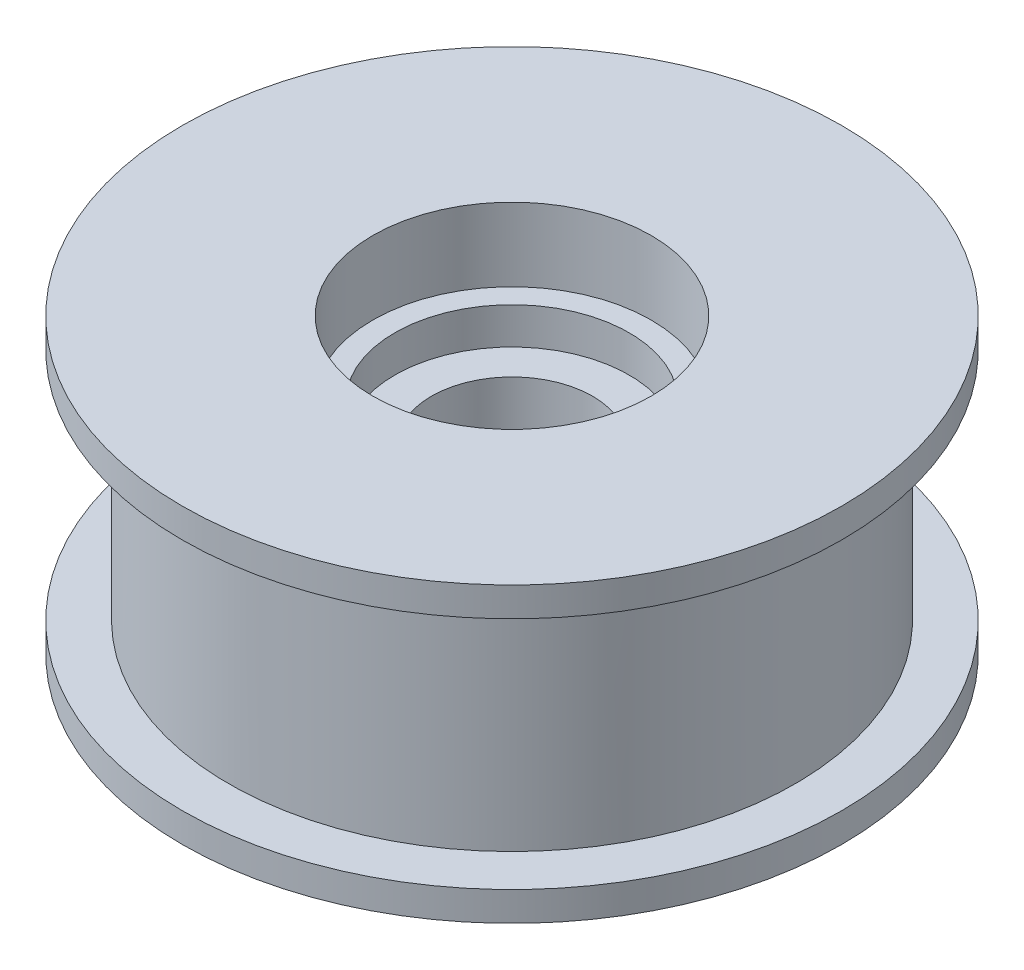
from build123d import *

# Parameters (mm, degrees)
SKETCH_1_R             = 19.325
SKETCH_1_R_2           = 2.5
EXTRUDE_1_DEPTH        = 16
SKETCH_2_R             = 22.5
SKETCH_2_R_2           = 2.5
EXTRUDE_2_DEPTH        = 2
SKETCH_3_R             = 22.5
SKETCH_3_R_2           = 2.5
EXTRUDE_3_DEPTH        = 2
SKETCH_4_R             = 5.5
CUT_EXTRUDE_1_DEPTH    = 20
HOLE_WIZARD_M3_1_D     = 2.5
HOLE_WIZARD_M3_1_DEPTH = 8.5
HOLE_WIZARD_M3_1_TIP   = 0.751075774
SKETCH_7_R             = 9.5
CUT_EXTRUDE_3_DEPTH    = 5
SKETCH_8_R             = 8
CUT_EXTRUDE_4_DEPTH    = 2.5


with BuildPart() as part:
    # 草图1 → 凸台-拉伸1 (new body)
    with BuildSketch(Plane(origin=(0, 0, 0), x_dir=(1, 0, 0), z_dir=(0, 1, 0))):
        Circle(SKETCH_1_R)
        Circle(SKETCH_1_R_2, mode=Mode.SUBTRACT)
    extrude(amount=EXTRUDE_1_DEPTH)

    # 草图2 → 凸台-拉伸2 (add)
    with BuildSketch(Plane(origin=(0, 16, 0), x_dir=(1, 0, 0), z_dir=(0, 1, 0))):
        Circle(SKETCH_2_R)
        Circle(SKETCH_2_R_2, mode=Mode.SUBTRACT)
    extrude(amount=EXTRUDE_2_DEPTH)

    # 草图3 → 凸台-拉伸3 (add)
    with BuildSketch(Plane.XZ):
        Circle(SKETCH_3_R)
        Circle(SKETCH_3_R_2, mode=Mode.SUBTRACT)
    extrude(amount=EXTRUDE_3_DEPTH)

    # 草图4 → 切除-拉伸1 (cut)
    with BuildSketch(Plane.XZ.offset(2)):
        Circle(SKETCH_4_R)
    extrude(amount=-CUT_EXTRUDE_1_DEPTH, mode=Mode.SUBTRACT)

    # M3 螺纹孔1
    with Locations(Plane(origin=(0, -2, 8), x_dir=(0, 0, -1), z_dir=(0, -1, 0))):
        with Locations((0, 0), (8, 8), (16, 0), (8, -8)):
            Hole(HOLE_WIZARD_M3_1_D / 2, depth=HOLE_WIZARD_M3_1_DEPTH)
            with Locations((0, 0, -(HOLE_WIZARD_M3_1_DEPTH + HOLE_WIZARD_M3_1_TIP / 2))):  # 118° drill point
                Cone(0, HOLE_WIZARD_M3_1_D / 2, HOLE_WIZARD_M3_1_TIP, mode=Mode.SUBTRACT)

    # 草图7 → 切除-拉伸3 (cut)
    with BuildSketch(Plane(origin=(0, 18, 0), x_dir=(1, 0, 0), z_dir=(0, 1, 0))):
        Circle(SKETCH_7_R)
    extrude(amount=-CUT_EXTRUDE_3_DEPTH, mode=Mode.SUBTRACT)

    # 草图8 → 切除-拉伸4 (cut)
    with BuildSketch(Plane(origin=(0, 13, 0), x_dir=(1, 0, 0), z_dir=(0, 1, 0))):
        Circle(SKETCH_8_R)
    extrude(amount=-CUT_EXTRUDE_4_DEPTH, mode=Mode.SUBTRACT)


solid = part.part
